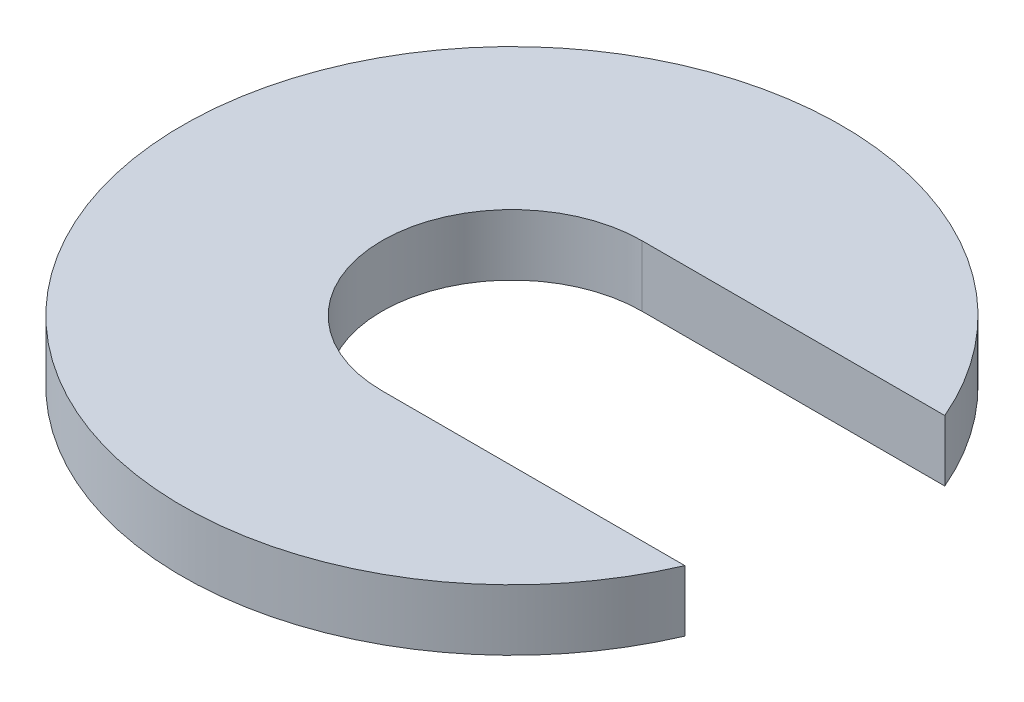
from build123d import *

# Parameters (mm, degrees)
BOSS_EXTRUDE1_DEPTH = 13.9


with BuildPart() as part:
    # Sketch1 → Boss-Extrude1 (new body)
    with BuildSketch(Plane(origin=(0, 0, 0), x_dir=(1, 0, 0), z_dir=(0, 1, 0))):
        with BuildLine():
            Line((0, 29.575), (68.922560711, 29.575))
            ThreePointArc((68.922560711, 29.575), (-75, 0), (68.922560711, -29.575))
            Line((68.922560711, -29.575), (0, -29.575))
            ThreePointArc((0, -29.575), (-29.575, 0), (0, 29.575))
        make_face()
    extrude(amount=BOSS_EXTRUDE1_DEPTH)


solid = part.part
